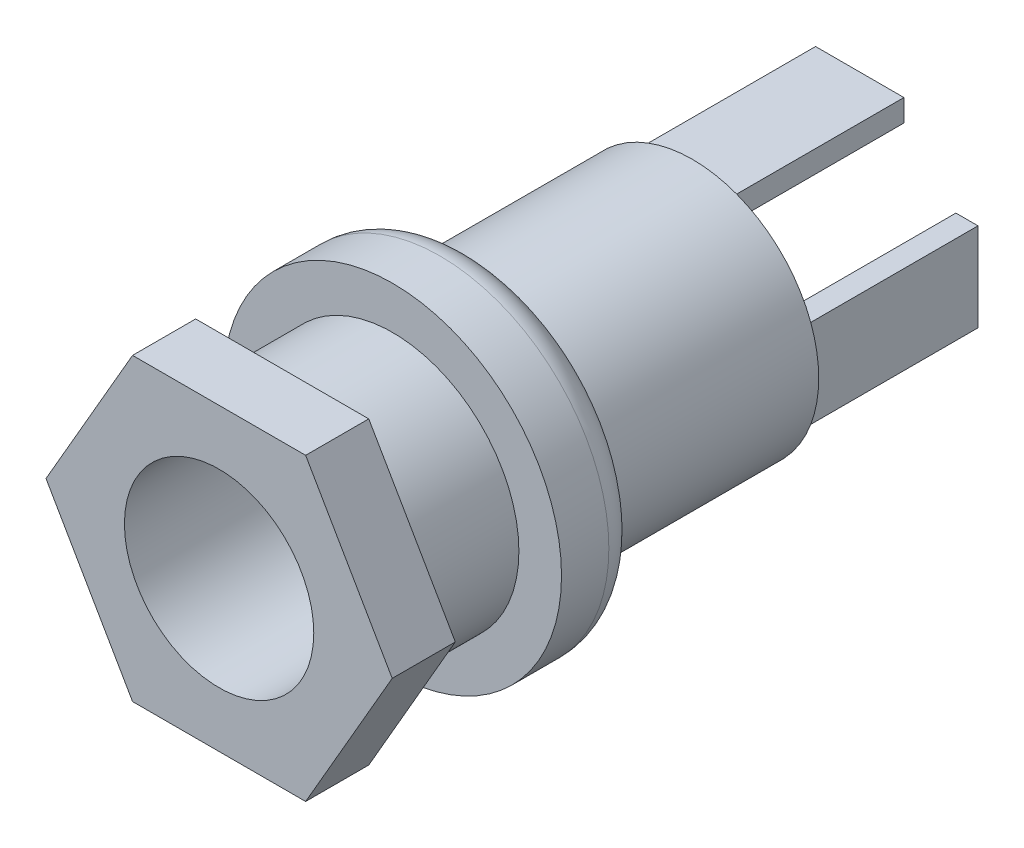
from build123d import *

# Parameters (mm, degrees)
CROQUIS1_R              = 4
CROQUIS1_R_2            = 3
SALIENTE_EXTRUIR1_DEPTH = 5.5
CROQUIS2_R              = 5.35
CROQUIS2_R_2            = 3
SALIENTE_EXTRUIR2_DEPTH = 2.5
REDONDEO1_R             = 1
CROQUIS3_R              = 4
SALIENTE_EXTRUIR3_DEPTH = 7
CROQUIS4_W              = 2.8
CROQUIS4_H              = 0.7
CROQUIS4_W_2            = 0.7
CROQUIS4_H_2            = 2.8
SALIENTE_EXTRUIR4_DEPTH = 5.3
CROQUIS5_R              = 4
SALIENTE_EXTRUIR5_DEPTH = 2


with BuildPart() as part:
    # Croquis1 → Saliente-Extruir1 (new body)
    with BuildSketch(Plane.XY):
        Circle(CROQUIS1_R)
        Circle(CROQUIS1_R_2, mode=Mode.SUBTRACT)
    extrude(amount=-SALIENTE_EXTRUIR1_DEPTH)

    # Croquis2 → Saliente-Extruir2 (add)
    with BuildSketch(Plane(origin=(0, 0, -5.5), x_dir=(-1, 0, 0), z_dir=(0, 0, -1))):
        Circle(CROQUIS2_R)
        with Locations(Location((0, 0, 0), (0, 0, 180))):
            Circle(CROQUIS2_R_2, mode=Mode.SUBTRACT)
    extrude(amount=SALIENTE_EXTRUIR2_DEPTH)

    # Redondeo1
    redondeo1_edges = [part.edges().sort_by_distance(p)[0] for p in [
        (5.35, 0, -8),
    ]]
    fillet(redondeo1_edges, radius=REDONDEO1_R)

    # Croquis3 → Saliente-Extruir3 (add)
    with BuildSketch(Plane(origin=(0, 0, -8), x_dir=(-1, 0, 0), z_dir=(0, 0, -1))):
        with Locations(Location((0, 0, 0), (0, 0, 180))):
            Circle(CROQUIS3_R)
    extrude(amount=SALIENTE_EXTRUIR3_DEPTH)

    # Croquis4 → Saliente-Extruir4 (add)
    with BuildSketch(Plane(origin=(0, 0, -15), x_dir=(-1, 0, 0), z_dir=(0, 0, -1))):
        with Locations((0, 3.396998799)):
            Rectangle(CROQUIS4_W, CROQUIS4_H)
        with Locations((-3.396998799, 0)):
            Rectangle(CROQUIS4_W_2, CROQUIS4_H_2)
        with Locations((3.396998799, 0)):
            Rectangle(CROQUIS4_W_2, CROQUIS4_H_2)
    extrude(amount=SALIENTE_EXTRUIR4_DEPTH)

    # Croquis5 → Saliente-Extruir5 (add)
    with BuildSketch(Plane.XY):
        Polygon((5.484827557, 0), (2.742413779, 4.75), (-2.742413779, 4.75), (-5.484827557, 0), (-2.742413779, -4.75), (2.742413779, -4.75), align=None)
        Circle(CROQUIS5_R, mode=Mode.SUBTRACT)
    extrude(amount=-SALIENTE_EXTRUIR5_DEPTH)


solid = part.part
